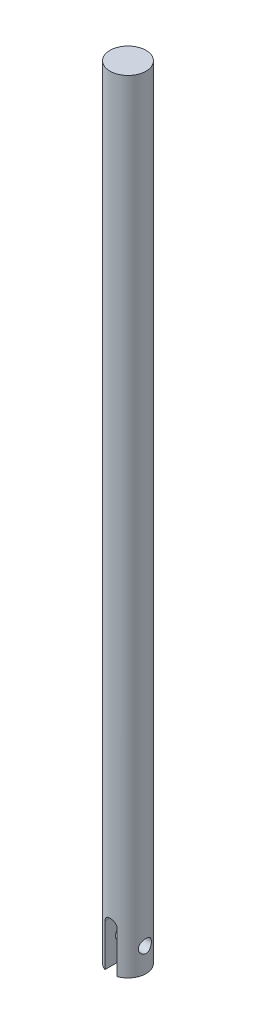
from build123d import *

# Parameters (mm, degrees)
SKETCH1_R               = 4.7625
BOSS_EXTRUDE1_DEPTH     = 206.375
CUT_EXTRUDE1_DEPTH      = 5.7625
CUT_EXTRUDE1_DEPTH_BACK = 5.7625
F_8_32_TAPPED_HOLE1_D   = 3.4544


with BuildPart() as part:
    # Sketch1 → Boss-Extrude1 (new body)
    with BuildSketch(Plane(origin=(0, 0, 0), x_dir=(1, 0, 0), z_dir=(0, 1, 0))):
        Circle(SKETCH1_R)
    extrude(amount=BOSS_EXTRUDE1_DEPTH)

    # Sketch2 → Cut-Extrude1 (cut, two sides)
    with BuildSketch(Plane.XY) as cut_extrude1_sk:
        with BuildLine():
            Line((-1.5875, -11.1125), (-1.5875, 11.1125))
            ThreePointArc((-1.5875, 11.1125), (0, 12.7), (1.5875, 11.1125))
            Line((1.5875, 11.1125), (1.5875, -11.1125))
            ThreePointArc((1.5875, -11.1125), (0, -12.7), (-1.5875, -11.1125))
        make_face()
    extrude(amount=CUT_EXTRUDE1_DEPTH, mode=Mode.SUBTRACT)
    extrude(cut_extrude1_sk.sketch, amount=-CUT_EXTRUDE1_DEPTH_BACK, mode=Mode.SUBTRACT)

    # #8-32 Tapped Hole1 (through all)
    with Locations(Plane(origin=(4.7625, 0, 0), x_dir=(0, 0, -1), z_dir=(1, 0, 0))):
        with Locations((0, 6.35)):
            Hole(F_8_32_TAPPED_HOLE1_D / 2)


solid = part.part
